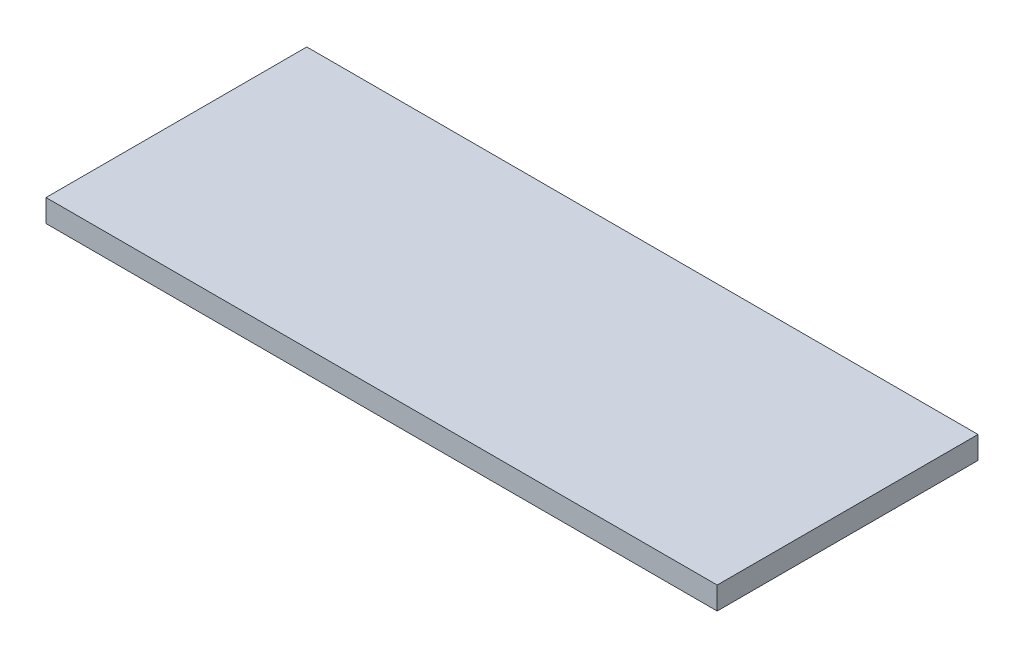
from build123d import *

# Parameters (mm, degrees)
SKETCH1_W           = 89.3
SKETCH1_H           = 34.7
BOSS_EXTRUDE1_DEPTH = 3


with BuildPart() as part:
    # Sketch1 → Boss-Extrude1 (new body)
    with BuildSketch(Plane(origin=(0, 0, 0), x_dir=(1, 0, 0), z_dir=(0, 1, 0))):
        Rectangle(SKETCH1_W, SKETCH1_H)
    extrude(amount=BOSS_EXTRUDE1_DEPTH)


solid = part.part
